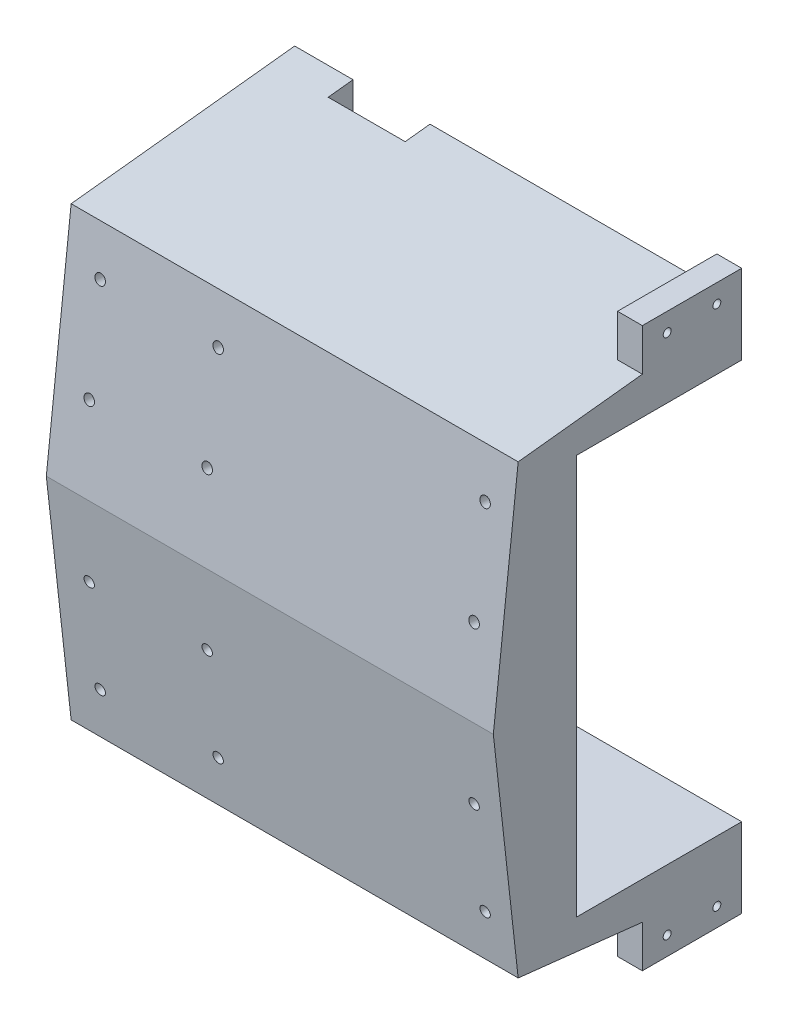
from build123d import *

# Parameters (mm, degrees)
BOSS_EXTRUDE1_DEPTH       = 10
BOSS_EXTRUDE2_DEPTH       = 170
BOSS_EXTRUDE3_REACH       = 182
BOSS_EXTRUDE4_REACH       = 102
SKETCH8_W                 = 170
SKETCH8_H                 = 9.5
SKETCH9_W                 = 31
SKETCH9_H                 = 19.5
CUT_EXTRUDE1_DEPTH        = 10
SKETCH10_R                = 2.1
CUT_EXTRUDE2_DEPTH        = 20
F_4_0MM_DOWEL_HOLE1_D     = 4.2
F_4_0MM_DOWEL_HOLE1_DEPTH = 10
F_4_0MM_DOWEL_HOLE1_TIP   = 1.2618073
SKETCH13_R                = 2.1
CUT_EXTRUDE3_DEPTH        = 10
BOSS_EXTRUDE5_DEPTH       = 10
CUT_EXTRUDE4_REACH        = 182
SKETCH15_R                = 1.6


with BuildPart() as part:
    # Sketch5 → Boss-Extrude1 (new body)
    with BuildSketch(Plane(origin=(0, 0, 0), x_dir=(0, 0, -1), z_dir=(1, 0, 0))):
        Polygon((0, 0), (10, 90), (100, 100), (100, -100), (10, -90), align=None)
    extrude(amount=-BOSS_EXTRUDE1_DEPTH)

    # Sketch6 → Boss-Extrude2 (add)
    with BuildSketch(Plane(origin=(0, 0, 0), x_dir=(0, 0, -1), z_dir=(1, 0, 0))):
        Polygon((0, 0), (10, -90), (100, -100), (100, -90), (19, -81), (10, 0), (19, 81), (100, 90), (100, 100), (10, 90), align=None)
    extrude(amount=BOSS_EXTRUDE2_DEPTH)

    # Sketch7 → Boss-Extrude3 (add, up to next)
    with BuildSketch(Plane(origin=(170, 0, 0), x_dir=(0, 0, -1), z_dir=(1, 0, 0)), mode=Mode.PRIVATE) as boss_extrude3_sk1:
        Polygon((19, 81), (10, 0), (19, -81), (33.5, -82.611111111), (33.5, 82.611111111), align=None)
    boss_extrude3_tool1 = extrude(boss_extrude3_sk1.sketch, amount=-BOSS_EXTRUDE3_REACH, mode=Mode.PRIVATE) - part.part
    add(boss_extrude3_tool1.solids().sort_by_distance((170, 0, -23.858858))[0])

    # Sketch8 → Boss-Extrude4 (add, up to next)
    with BuildSketch(Plane(origin=(0, 0, -100), x_dir=(-1, 0, 0), z_dir=(0, 0, -1)), mode=Mode.PRIVATE) as boss_extrude4_sk1:
        with Locations((-85, 85.25)):
            Rectangle(SKETCH8_W, SKETCH8_H)
    boss_extrude4_tool1 = extrude(boss_extrude4_sk1.sketch, amount=-BOSS_EXTRUDE4_REACH, mode=Mode.PRIVATE) - part.part
    add(boss_extrude4_tool1.solids().sort_by_distance((85, 85.25, -100))[0])
    # Sketch8 → Boss-Extrude4 (add, up to next)
    with BuildSketch(Plane(origin=(0, 0, -100), x_dir=(-1, 0, 0), z_dir=(0, 0, -1)), mode=Mode.PRIVATE) as boss_extrude4_sk2:
        with Locations((-85, -85.25)):
            Rectangle(SKETCH8_W, SKETCH8_H)
    boss_extrude4_tool2 = extrude(boss_extrude4_sk2.sketch, amount=-BOSS_EXTRUDE4_REACH, mode=Mode.PRIVATE) - part.part
    add(boss_extrude4_tool2.solids().sort_by_distance((85, -85.25, -100))[0])

    # Sketch9 → Cut-Extrude1 (cut)
    with BuildSketch(Plane(origin=(0, 0, -100), x_dir=(-1, 0, 0), z_dir=(0, 0, -1))):
        with Locations((-29, -90.25)):
            Rectangle(SKETCH9_W, SKETCH9_H)
        with Locations((-29, 90.25)):
            Rectangle(SKETCH9_W, SKETCH9_H)
    extrude(amount=-CUT_EXTRUDE1_DEPTH, mode=Mode.SUBTRACT)

    # Sketch10 → Cut-Extrude2 (cut)
    with BuildSketch(Plane(origin=(0, 0, -100), x_dir=(-1, 0, 0), z_dir=(0, 0, -1))):
        with Locations((-22, -90.25)):
            Circle(SKETCH10_R)
        with Locations((-22, 90.25)):
            Circle(SKETCH10_R)
        with Locations((-36, -90.25)):
            Circle(SKETCH10_R)
        with Locations((-36, 90.25)):
            Circle(SKETCH10_R)
    extrude(amount=-CUT_EXTRUDE2_DEPTH, mode=Mode.SUBTRACT)

    # Ø4.0mm Dowel Hole1
    with Locations(Plane(origin=(0, 0, -100), x_dir=(-1, 0, 0), z_dir=(0, 0, -1))):
        with Locations((-157.5, 90.25), (-137.5, 90.25), (-117.5, 90.25), (-97.5, 90.25), (-77.5, 90.25), (-57.5, 90.25), (-157.5, -90.25), (-137.5, -90.25), (-117.5, -90.25), (-97.5, -90.25), (-77.5, -90.25), (-57.5, -90.25)):
            Hole(F_4_0MM_DOWEL_HOLE1_D / 2, depth=F_4_0MM_DOWEL_HOLE1_DEPTH)
            with Locations((0, 0, -(F_4_0MM_DOWEL_HOLE1_DEPTH + F_4_0MM_DOWEL_HOLE1_TIP / 2))):  # 118° drill point
                Cone(0, F_4_0MM_DOWEL_HOLE1_D / 2, F_4_0MM_DOWEL_HOLE1_TIP, mode=Mode.SUBTRACT)

    # Sketch13 → Cut-Extrude3 (cut)
    with BuildSketch(Plane(origin=(0, 0, 0), x_dir=(1, 0, 0), z_dir=(0, -0.110431526, 0.993883735))):
        with Locations((3.75, -31.944444444)):
            Circle(SKETCH13_R)
        with Locations((51.25, -31.944444444)):
            Circle(SKETCH13_R)
        with Locations((3.75, -71.944444444)):
            Circle(SKETCH13_R)
        with Locations((51.25, -71.944444444)):
            Circle(SKETCH13_R)
        with Locations((158.75, -31.888888889)):
            Circle(SKETCH13_R)
        with Locations((158.75, -71.888888889)):
            Circle(SKETCH13_R)
    cut_extrude3 = extrude(amount=-CUT_EXTRUDE3_DEPTH, mode=Mode.SUBTRACT)

    # Mirror1: Cut-Extrude3 across plane
    add(cut_extrude3.mirror(Plane.ZX), mode=Mode.SUBTRACT)

    # Sketch14 → Boss-Extrude5 (add)
    with BuildSketch(Plane(origin=(170, 0, 0), x_dir=(0, 0, -1), z_dir=(1, 0, 0))):
        Polygon((60, 95.555555556), (100, 100), (100, 112.5), (60, 112.5), align=None)
        Polygon((100, -100), (100, -112.5), (60, -112.5), (60, -95.555555556), align=None)
    extrude(amount=-BOSS_EXTRUDE5_DEPTH)

    # Sketch15 → Cut-Extrude4 (cut, up to next)
    with BuildSketch(Plane(origin=(170, 0, 0), x_dir=(0, 0, -1), z_dir=(1, 0, 0)), mode=Mode.PRIVATE) as cut_extrude4_sk1:
        with Locations((70, -105)):
            Circle(SKETCH15_R)
    cut_extrude4_tool1 = extrude(cut_extrude4_sk1.sketch, amount=-CUT_EXTRUDE4_REACH, mode=Mode.PRIVATE) & part.part
    add(cut_extrude4_tool1.solids().sort_by_distance((170, -105, -70))[0], mode=Mode.SUBTRACT)
    # Sketch15 → Cut-Extrude4 (cut, up to next)
    with BuildSketch(Plane(origin=(170, 0, 0), x_dir=(0, 0, -1), z_dir=(1, 0, 0)), mode=Mode.PRIVATE) as cut_extrude4_sk2:
        with Locations((90, -105)):
            Circle(SKETCH15_R)
    cut_extrude4_tool2 = extrude(cut_extrude4_sk2.sketch, amount=-CUT_EXTRUDE4_REACH, mode=Mode.PRIVATE) & part.part
    add(cut_extrude4_tool2.solids().sort_by_distance((170, -105, -90))[0], mode=Mode.SUBTRACT)
    # Sketch15 → Cut-Extrude4 (cut, up to next)
    with BuildSketch(Plane(origin=(170, 0, 0), x_dir=(0, 0, -1), z_dir=(1, 0, 0)), mode=Mode.PRIVATE) as cut_extrude4_sk3:
        with Locations((90, 105)):
            Circle(SKETCH15_R)
    cut_extrude4_tool3 = extrude(cut_extrude4_sk3.sketch, amount=-CUT_EXTRUDE4_REACH, mode=Mode.PRIVATE) & part.part
    add(cut_extrude4_tool3.solids().sort_by_distance((170, 105, -90))[0], mode=Mode.SUBTRACT)
    # Sketch15 → Cut-Extrude4 (cut, up to next)
    with BuildSketch(Plane(origin=(170, 0, 0), x_dir=(0, 0, -1), z_dir=(1, 0, 0)), mode=Mode.PRIVATE) as cut_extrude4_sk4:
        with Locations((70, 105)):
            Circle(SKETCH15_R)
    cut_extrude4_tool4 = extrude(cut_extrude4_sk4.sketch, amount=-CUT_EXTRUDE4_REACH, mode=Mode.PRIVATE) & part.part
    add(cut_extrude4_tool4.solids().sort_by_distance((170, 105, -70))[0], mode=Mode.SUBTRACT)


solid = part.part
